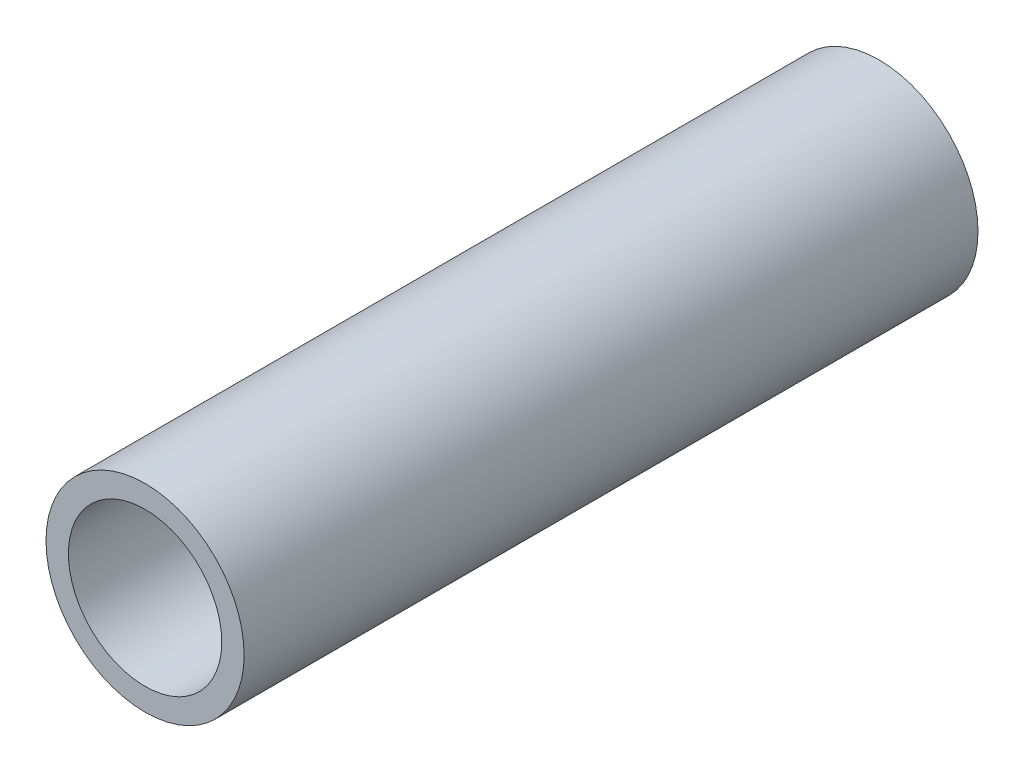
from build123d import *

# Parameters (mm, degrees)
SKETCH1_R           = 5.4
SKETCH1_R_2         = 4.18
BOSS_EXTRUDE1_DEPTH = 40
CUT_EXTRUDE1_REACH  = 7.4
SKETCH2_R           = 3


with BuildPart() as part:
    # Sketch1 → Boss-Extrude1 (new body)
    with BuildSketch(Plane.XY):
        Circle(SKETCH1_R)
        Circle(SKETCH1_R_2, mode=Mode.SUBTRACT)
    extrude(amount=BOSS_EXTRUDE1_DEPTH)

    # Sketch2 → Cut-Extrude1 (cut, up to next)
    with BuildSketch(Plane(origin=(0, 0, 0), x_dir=(0, 0, -1), z_dir=(1, 0, 0)), mode=Mode.PRIVATE) as cut_extrude1_sk1:
        with Locations((-20, 0)):
            Circle(SKETCH2_R)
    cut_extrude1_tool1 = extrude(cut_extrude1_sk1.sketch, amount=-CUT_EXTRUDE1_REACH, mode=Mode.PRIVATE) & part.part
    add(cut_extrude1_tool1.solids().sort_by_distance((0, 0, 20))[0], mode=Mode.SUBTRACT)


solid = part.part
